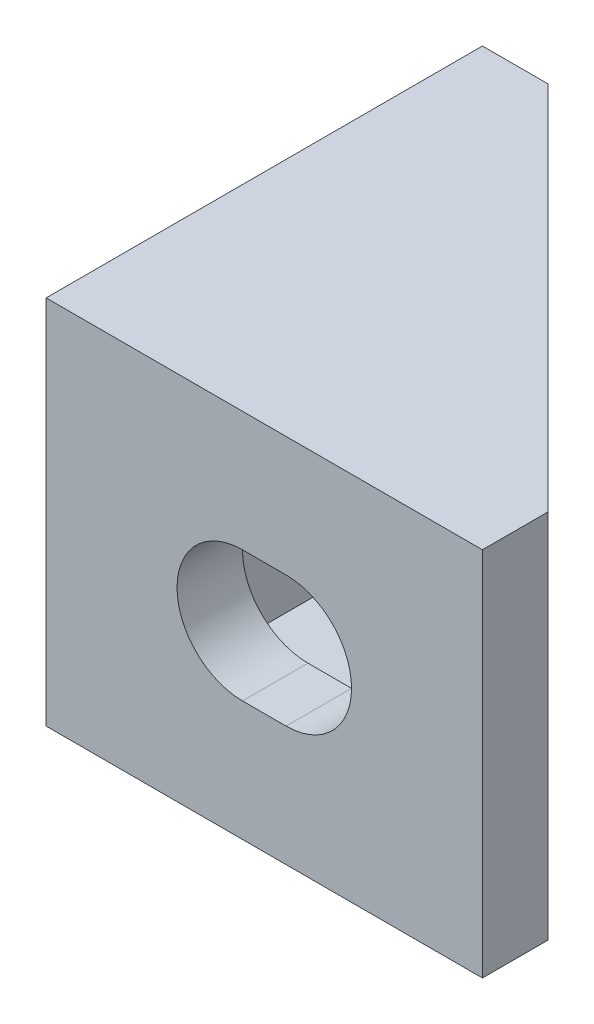
from build123d import *

# Parameters (mm, degrees)
BOSS_EXTRUDE1_DEPTH = 17
SKETCH2_W           = 17
SKETCH2_H           = 13
CUT_EXTRUDE1_DEPTH  = 17
CUT_EXTRUDE2_REACH  = 5
CUT_EXTRUDE3_REACH  = 5


with BuildPart() as part:
    # Sketch1 → Boss-Extrude1 (new body)
    with BuildSketch(Plane(origin=(0, 0, 0), x_dir=(1, 0, 0), z_dir=(0, 1, 0))):
        Polygon((0, 0), (20, 0), (20, 3), (3, 20), (0, 20), align=None)
    extrude(amount=BOSS_EXTRUDE1_DEPTH)

    # Sketch2 → Cut-Extrude1 (cut)
    with BuildSketch(Plane(origin=(0, 0, -20), x_dir=(-1, 0, 0), z_dir=(0, 0, -1))):
        with Locations((-11.5, 8.5)):
            Rectangle(SKETCH2_W, SKETCH2_H)
    extrude(amount=-CUT_EXTRUDE1_DEPTH, mode=Mode.SUBTRACT)

    # Sketch3 → Cut-Extrude2 (cut, up to next)
    with BuildSketch(Plane(origin=(3, 0, 0), x_dir=(0, 0, -1), z_dir=(1, 0, 0)), mode=Mode.PRIVATE) as cut_extrude2_sk1:
        with BuildLine():
            Line((9, 11.5), (11, 11.5))
            ThreePointArc((11, 11.5), (14, 8.5), (11, 5.5))
            Line((11, 5.5), (9, 5.5))
            ThreePointArc((9, 5.5), (6, 8.5), (9, 11.5))
        make_face()
    cut_extrude2_tool1 = extrude(cut_extrude2_sk1.sketch, amount=-CUT_EXTRUDE2_REACH, mode=Mode.PRIVATE) & part.part
    add(cut_extrude2_tool1.solids().sort_by_distance((3, 8.5, -10))[0], mode=Mode.SUBTRACT)

    # Sketch4 → Cut-Extrude3 (cut, up to next)
    with BuildSketch(Plane(origin=(0, 0, -3), x_dir=(-1, 0, 0), z_dir=(0, 0, -1)), mode=Mode.PRIVATE) as cut_extrude3_sk1:
        with BuildLine():
            Line((-11, 11.5), (-9, 11.5))
            ThreePointArc((-9, 11.5), (-6, 8.5), (-9, 5.5))
            Line((-9, 5.5), (-11, 5.5))
            ThreePointArc((-11, 5.5), (-14, 8.5), (-11, 11.5))
        make_face()
    cut_extrude3_tool1 = extrude(cut_extrude3_sk1.sketch, amount=-CUT_EXTRUDE3_REACH, mode=Mode.PRIVATE) & part.part
    add(cut_extrude3_tool1.solids().sort_by_distance((10, 8.5, -3))[0], mode=Mode.SUBTRACT)


solid = part.part
